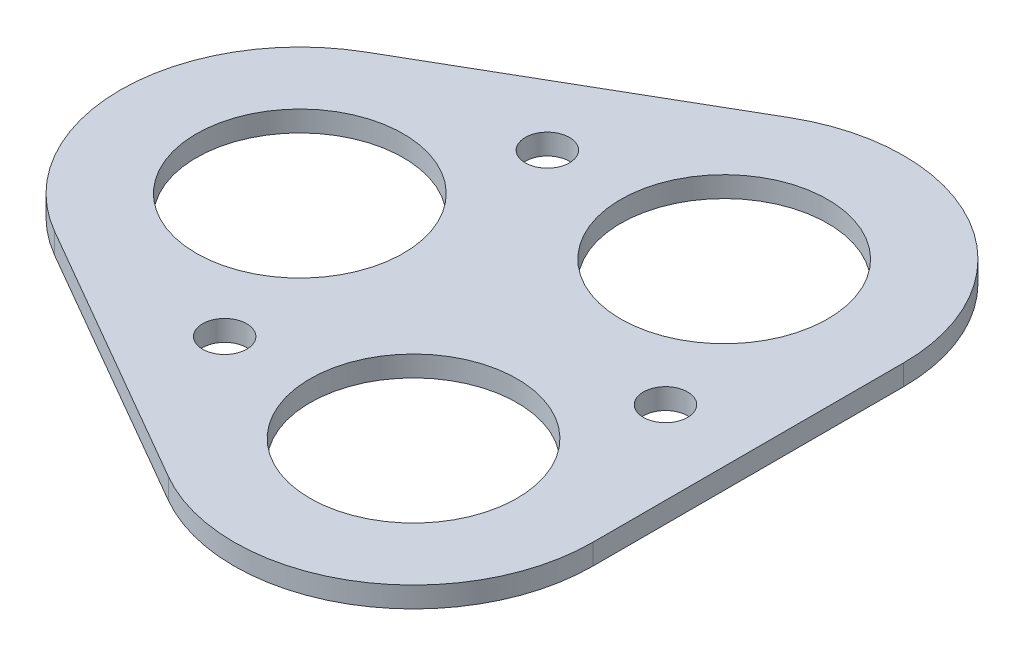
from build123d import *

# Parameters (mm, degrees)
SKETCH1_R           = 7.5
SKETCH1_R_2         = 1.6
SKETCH1_R_3         = 1.599999998
BOSS_EXTRUDE1_DEPTH = 1.5


with BuildPart() as part:
    # Sketch1 → Boss-Extrude1 (new body)
    with BuildSketch(Plane(origin=(0, 0, 0), x_dir=(1, 0, 0), z_dir=(0, 1, 0))):
        with BuildLine():
            Line((-15.804326324, -11.258330249), (3.681245261, -22.508330249))
            ThreePointArc((3.681245261, -22.508330249), (16.681245261, -22.508330249), (23.181245261, -11.25))
            Line((23.181245261, -11.25), (23.181245261, 11.25))
            ThreePointArc((23.181245261, 11.25), (16.681245261, 22.508330249), (3.681245261, 22.508330249))
            Line((3.681245261, 22.508330249), (-15.804326324, 11.258330249))
            ThreePointArc((-15.804326324, 11.258330249), (-22.304326324, 0), (-15.804326324, -11.258330249))
        make_face()
        with Locations((-9.304326324, 0)):
            Circle(SKETCH1_R, mode=Mode.SUBTRACT)
        with Locations((-3.06154027, 11.687177858)):
            Circle(SKETCH1_R_2, mode=Mode.SUBTRACT)
        with Locations((17.181245264, 0)):
            Circle(SKETCH1_R_3, mode=Mode.SUBTRACT)
        with Locations((10.181245261, -11.25)):
            Circle(SKETCH1_R, mode=Mode.SUBTRACT)
        with Locations((10.181245261, 11.25)):
            Circle(SKETCH1_R, mode=Mode.SUBTRACT)
        with Locations((-3.06154027, -11.687177373)):
            Circle(SKETCH1_R_2, mode=Mode.SUBTRACT)
    extrude(amount=BOSS_EXTRUDE1_DEPTH)


solid = part.part
